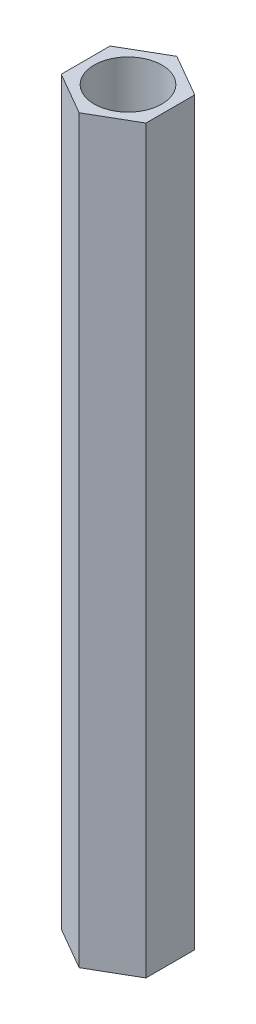
from build123d import *

# Parameters (mm, degrees)
EXTRUDE_1_DEPTH     = 35
SKETCH_2_R          = 1.6
CUT_EXTRUDE_1_DEPTH = 36


with BuildPart() as part:
    # 草图1 → 凸台-拉伸1 (new body)
    with BuildSketch(Plane(origin=(0, 0, 0), x_dir=(1, 0, 0), z_dir=(0, 1, 0))):
        Polygon((2.000369925, -1.154059572), (1.99962987, 1.155341386), (-0.000740056, 2.309400958), (-2.000369925, 1.154059572), (-1.99962987, -1.155341386), (0.000740056, -2.309400958), align=None)
    extrude(amount=EXTRUDE_1_DEPTH)

    # 草图2 → 切除-拉伸1 (cut, through all)
    with BuildSketch(Plane(origin=(0, 35, 0), x_dir=(1, 0, 0), z_dir=(0, 1, 0))):
        Circle(SKETCH_2_R)
    extrude(amount=-CUT_EXTRUDE_1_DEPTH, mode=Mode.SUBTRACT)


solid = part.part
